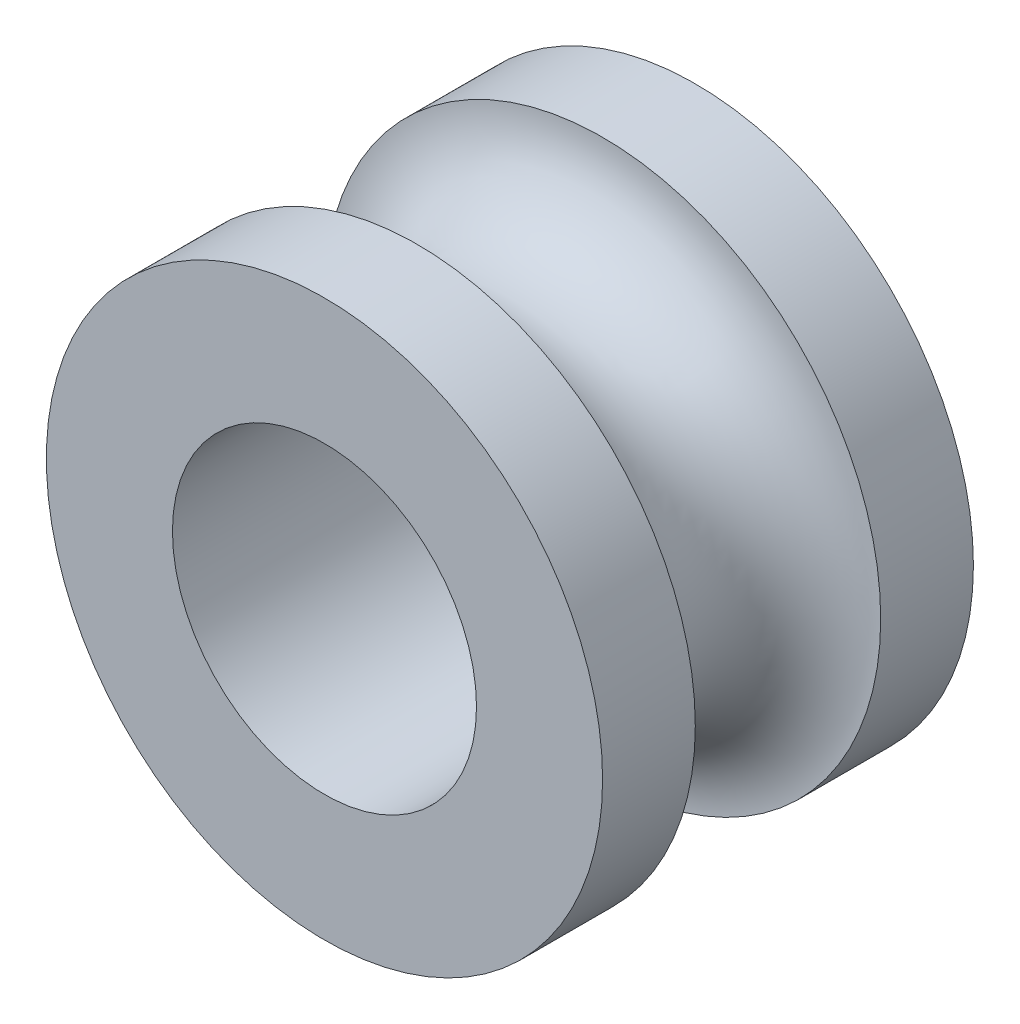
from build123d import *

# Parameters (mm, degrees)
SKETCH1_R            = 3.75
SKETCH1_R_2          = 2.05
BOSS_EXTRUDE1_DEPTH  = 2.5
CUT_SWEEP1_PROFILE_R = 1.25


with BuildPart() as part:
    # Sketch1 → Boss-Extrude1 (new body, symmetric)
    with BuildSketch(Plane.XY):
        Circle(SKETCH1_R)
        Circle(SKETCH1_R_2, mode=Mode.SUBTRACT)
    extrude(amount=BOSS_EXTRUDE1_DEPTH, both=True)

    # Cut-Sweep1: sweep along a path in Sketch2
    with BuildLine(Plane.XY) as cut_sweep1_path:
        CenterArc((0, 0), 3.75, 0, 360)
    # Cut-Sweep1 profile (on start of the path) → Cut-Sweep1 (sweep, cut)
    with BuildSketch(Plane(origin=(3.75, 0, 0), x_dir=(0, 0, 1), z_dir=(0, 1, 0))):
        Circle(CUT_SWEEP1_PROFILE_R)
    sweep(path=cut_sweep1_path.line, mode=Mode.SUBTRACT)


solid = part.part
